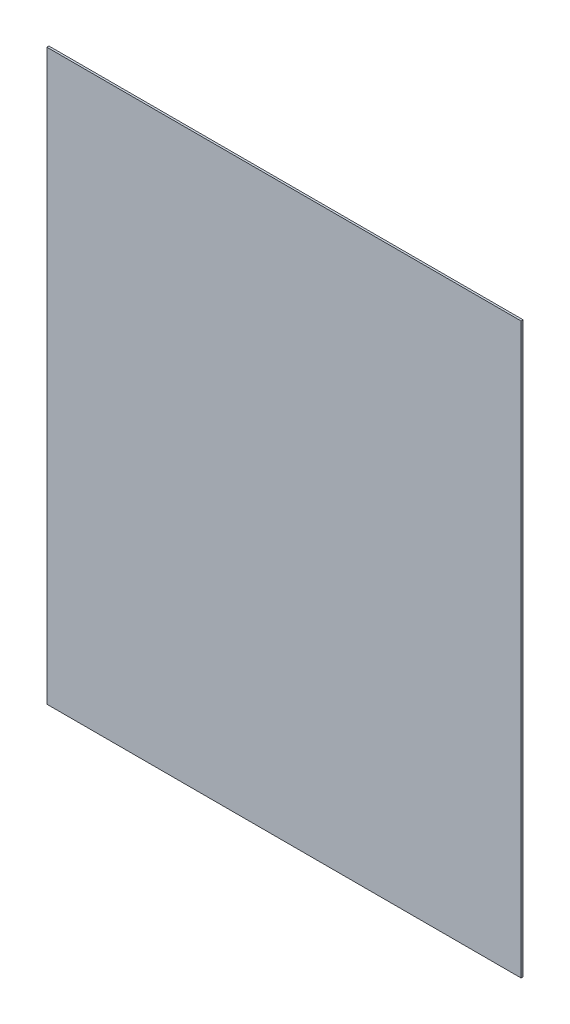
from build123d import *

# Parameters (mm, degrees)
SKETCH1_W           = 762
SKETCH1_H           = 914.4
BOSS_EXTRUDE1_DEPTH = 3.302


with BuildPart() as part:
    # Sketch1 → Boss-Extrude1 (new body)
    with BuildSketch(Plane.XY):
        with Locations((-407.924, 1322.324)):
            Rectangle(SKETCH1_W, SKETCH1_H)
    extrude(amount=-BOSS_EXTRUDE1_DEPTH)


solid = part.part
